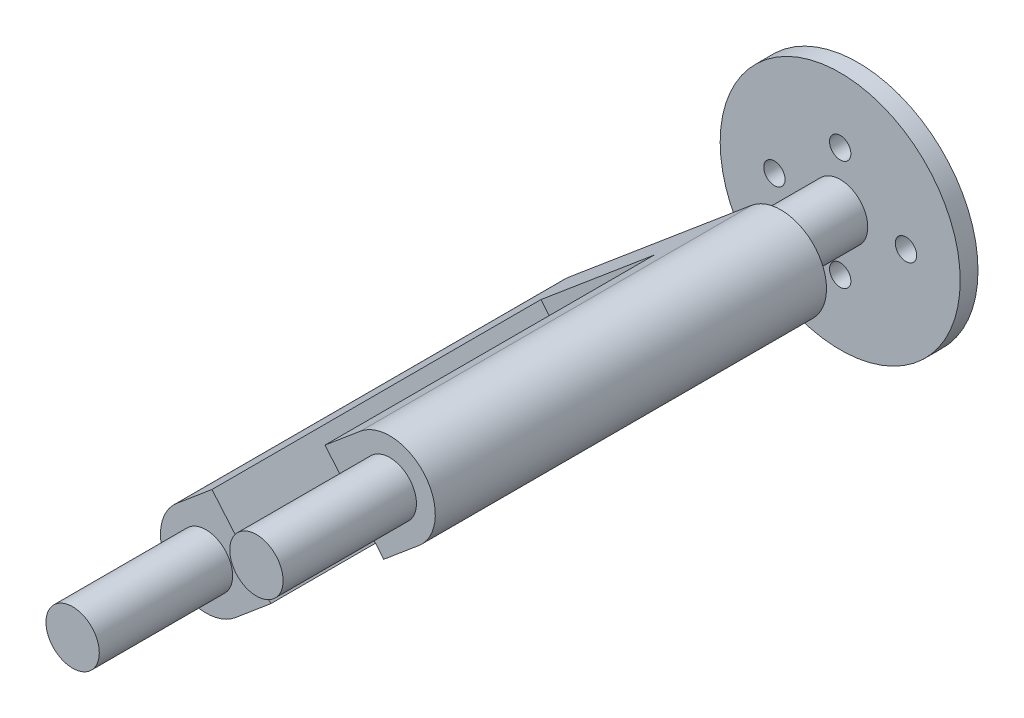
from build123d import *

# Parameters (mm, degrees)
SKETCH1_R                = 17.145
SKETCH1_R_2              = 3.937
SKETCH1_R_3              = 1.524
BOSS_EXTRUDE1_DEPTH      = 2.54
SKETCH2_R                = 3.937
BOSS_EXTRUDE2_DEPTH      = 73.66
BOSS_EXTRUDE2_DEPTH_BACK = 2.54
BOSS_EXTRUDE8_DEPTH      = 3.81
BOSS_EXTRUDE8_DEPTH_BACK = 52.07
SKETCH10_R               = 3.81
BOSS_EXTRUDE9_DEPTH      = 19.05
CUT_EXTRUDE1_DEPTH       = 46.99
FILLET3_R                = 2.54


with BuildPart() as part:
    # Sketch1 → Boss-Extrude1 (new body)
    with BuildSketch(Plane.XY):
        Circle(SKETCH1_R)
        Circle(SKETCH1_R_2, mode=Mode.SUBTRACT)
        with Locations((0, 7.874)):
            Circle(SKETCH1_R_3, mode=Mode.SUBTRACT)
        with Locations((0, -7.874)):
            Circle(SKETCH1_R_3, mode=Mode.SUBTRACT)
        with Locations((-9.398, 0)):
            Circle(SKETCH1_R_3, mode=Mode.SUBTRACT)
        with Locations((9.398, 0)):
            Circle(SKETCH1_R_3, mode=Mode.SUBTRACT)
    extrude(amount=BOSS_EXTRUDE1_DEPTH)

    # Sketch2 → Boss-Extrude2 (add, two sides)
    with BuildSketch(Plane.XY.offset(2.54)) as boss_extrude2_sk:
        Circle(SKETCH2_R)
    extrude(amount=BOSS_EXTRUDE2_DEPTH)
    extrude(boss_extrude2_sk.sketch, amount=-BOSS_EXTRUDE2_DEPTH_BACK)

    # Sketch9 → Boss-Extrude8 (add, two sides)
    with BuildSketch(Plane.XY.offset(76.2)) as boss_extrude8_sk:
        with BuildLine():
            Line((17.310299419, 6.04983425), (-8.943054295, -16.008395932))
            ThreePointArc((-8.943054295, -16.008395932), (-18.105957698, -15.212737654), (-17.310299419, -6.04983425))
            Line((-17.310299419, -6.04983425), (8.943054295, 16.008395932))
            ThreePointArc((8.943054295, 16.008395932), (18.105957698, 15.212737654), (17.310299419, 6.04983425))
        make_face()
    extrude(amount=BOSS_EXTRUDE8_DEPTH)
    extrude(boss_extrude8_sk.sketch, amount=-BOSS_EXTRUDE8_DEPTH_BACK)

    # Sketch10 → Boss-Extrude9 (add)
    with BuildSketch(Plane.XY.offset(80.01)):
        with Locations((13.126676857, 11.029115091)):
            Circle(SKETCH10_R)
        with Locations((-13.126676857, -11.029115091)):
            Circle(SKETCH10_R)
    extrude(amount=BOSS_EXTRUDE9_DEPTH)

    # Sketch11 → Cut-Extrude1 (cut)
    with BuildSketch(Plane.XY.offset(80.01)):
        Polygon((3.374041748, 12.335861743), (-12.725218051, -1.275330633), (-3.374041748, -12.335861743), (12.725218051, 1.275330633), align=None)
    extrude(amount=-CUT_EXTRUDE1_DEPTH, mode=Mode.SUBTRACT)

    # Fillet3
    fillet3_edges = [part.edges().sort_by_distance(p)[0] for p in [
        (-3.937, 0, 24.13),
    ]]
    fillet(fillet3_edges, radius=FILLET3_R)


solid = part.part
